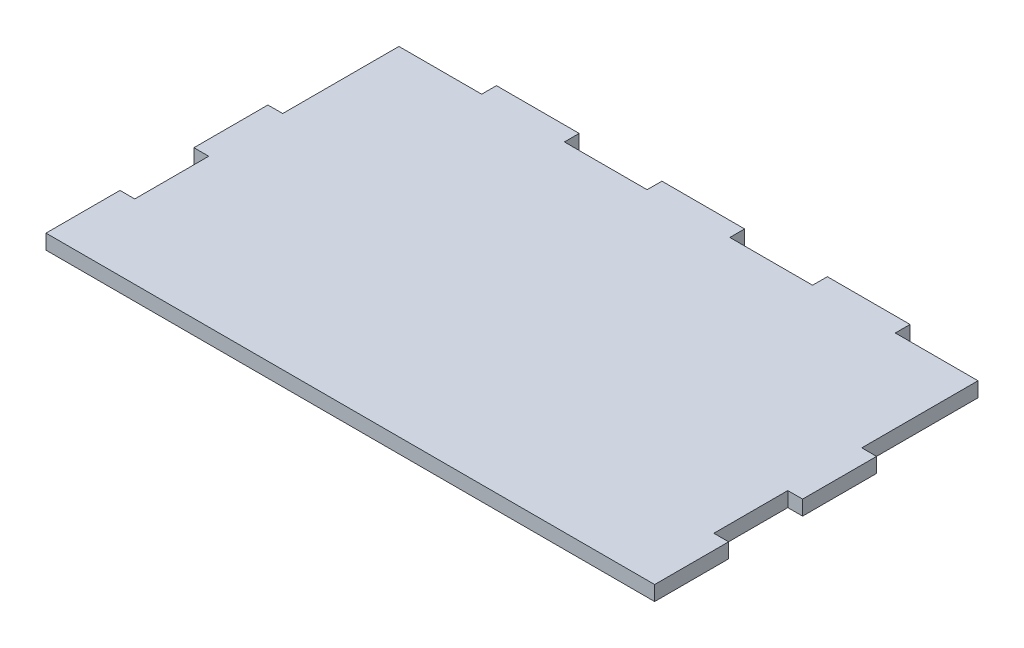
from build123d import *

# Parameters (mm, degrees)
SKETCH1_W           = 68.5
SKETCH1_H           = 40
SKETCH1_W_2         = 1.75
SKETCH1_H_2         = 8.75
SKETCH1_W_3         = 9.785714285
SKETCH1_H_3         = 1.75
SKETCH1_W_4         = 9.785714286
BOSS_EXTRUDE1_DEPTH = 1.75


with BuildPart() as part:
    # Sketch1 → Boss-Extrude1 (new body)
    with BuildSketch(Plane(origin=(0, 0, 0), x_dir=(1, 0, 0), z_dir=(0, 1, 0))):
        with Locations((34.25, 20)):
            Rectangle(SKETCH1_W, SKETCH1_H)
        with Locations((-0.875, 21.875)):
            Rectangle(SKETCH1_W_2, SKETCH1_H_2)
        with Locations((-0.875, 4.375)):
            Rectangle(SKETCH1_W_2, SKETCH1_H_2)
        with Locations((14.678571429, 40.875)):
            Rectangle(SKETCH1_W_3, SKETCH1_H_3)
        with Locations((34.25, 40.875)):
            Rectangle(SKETCH1_W_4, SKETCH1_H_3)
        with Locations((53.821428572, 40.875)):
            Rectangle(SKETCH1_W_3, SKETCH1_H_3)
        with Locations((69.375, 21.875)):
            Rectangle(SKETCH1_W_2, SKETCH1_H_2)
        with Locations((69.375, 4.375)):
            Rectangle(SKETCH1_W_2, SKETCH1_H_2)
    extrude(amount=BOSS_EXTRUDE1_DEPTH)


solid = part.part
